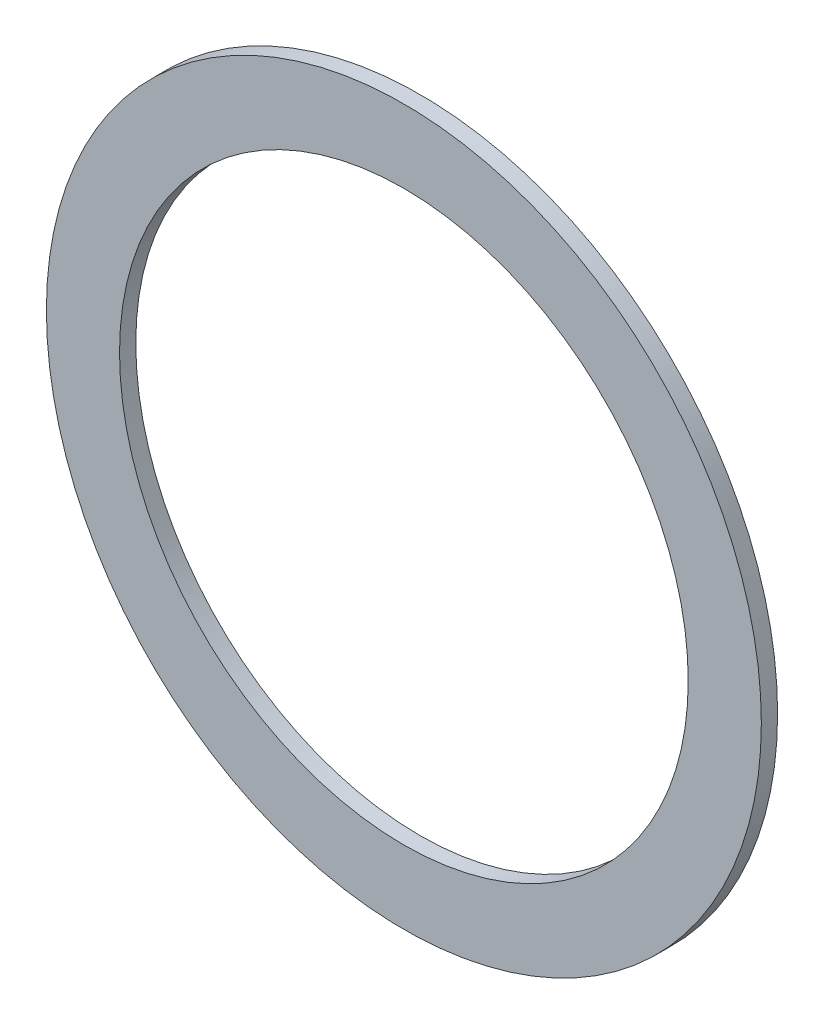
from build123d import *

# Parameters (mm, degrees)
SZKIC1_R                          = 22
SZKIC1_R_2                        = 17.5
WYCI_GNI_CIE_CIENKA_CIANKA1_DEPTH = 1


with BuildPart() as part:
    # Szkic1 → Wyciągnięcie-cienka ścianka1 (new body)
    with BuildSketch(Plane.XY):
        Circle(SZKIC1_R)
        Circle(SZKIC1_R_2, mode=Mode.SUBTRACT)
    extrude(amount=WYCI_GNI_CIE_CIENKA_CIANKA1_DEPTH)


solid = part.part
